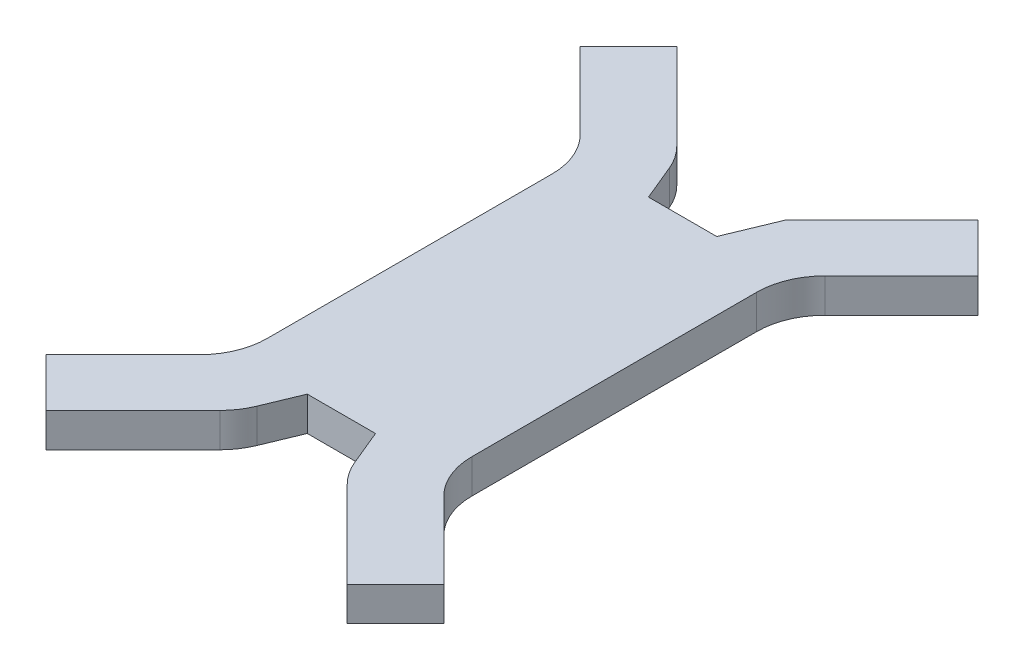
from build123d import *

# Parameters (mm, degrees)
BOSS_EXTRUDE1_DEPTH = 5


with BuildPart() as part:
    # Sketch1 → Boss-Extrude1 (new body)
    with BuildSketch(Plane(origin=(0, 0, 0), x_dir=(1, 0, 0), z_dir=(0, 1, 0))):
        with BuildLine():
            Line((-65.607722973, 30.584051311), (-58.536655161, 37.655119123))
            Line((-58.536655161, 37.655119123), (-45.801042376, 24.919506337))
            ThreePointArc((-45.801042376, 24.919506337), (-44.557414065, 23.404140856), (-43.633314863, 21.675272849))
            Line((-43.633314863, 21.675272849), (-41.465587349, 16.441915687))
            Line((-41.465587349, 16.441915687), (-31.465587349, 16.441915687))
            Line((-31.465587349, 16.441915687), (-28.536655161, 23.512983499))
            Line((-28.536655161, 23.512983499), (-14.394519538, 37.655119123))
            Line((-14.394519538, 37.655119123), (-7.323451726, 30.584051311))
            Line((-7.323451726, 30.584051311), (-18.536655161, 19.370847875))
            ThreePointArc((-18.536655161, 19.370847875), (-20.704382675, 16.126614387), (-21.465587349, 12.299780063))
            Line((-21.465587349, 12.299780063), (-21.465587349, -29.415948689))
            ThreePointArc((-21.465587349, -29.415948689), (-20.704382675, -33.242783013), (-18.536655161, -36.487016501))
            Line((-18.536655161, -36.487016501), (-7.323451726, -47.700219937))
            Line((-7.323451726, -47.700219937), (-14.394519538, -54.771287748))
            Line((-14.394519538, -54.771287748), (-27.130132323, -42.035674963))
            ThreePointArc((-27.130132323, -42.035674963), (-28.373760634, -40.520309481), (-29.297859836, -38.791441475))
            Line((-29.297859836, -38.791441475), (-31.465587349, -33.558084313))
            Line((-31.465587349, -33.558084313), (-41.465587349, -33.558084313))
            Line((-41.465587349, -33.558084313), (-43.633314863, -38.791441475))
            ThreePointArc((-43.633314863, -38.791441475), (-44.557414065, -40.520309481), (-45.801042376, -42.035674963))
            Line((-45.801042376, -42.035674963), (-58.536655161, -54.771287748))
            Line((-58.536655161, -54.771287748), (-65.607722973, -47.700219937))
            Line((-65.607722973, -47.700219937), (-54.394519538, -36.487016501))
            ThreePointArc((-54.394519538, -36.487016501), (-52.226792024, -33.242783013), (-51.465587349, -29.415948689))
            Line((-51.465587349, -29.415948689), (-51.465587349, 12.299780063))
            ThreePointArc((-51.465587349, 12.299780063), (-52.226792024, 16.126614387), (-54.394519538, 19.370847875))
            Line((-54.394519538, 19.370847875), (-65.607722973, 30.584051311))
        make_face()
    extrude(amount=BOSS_EXTRUDE1_DEPTH)


solid = part.part
